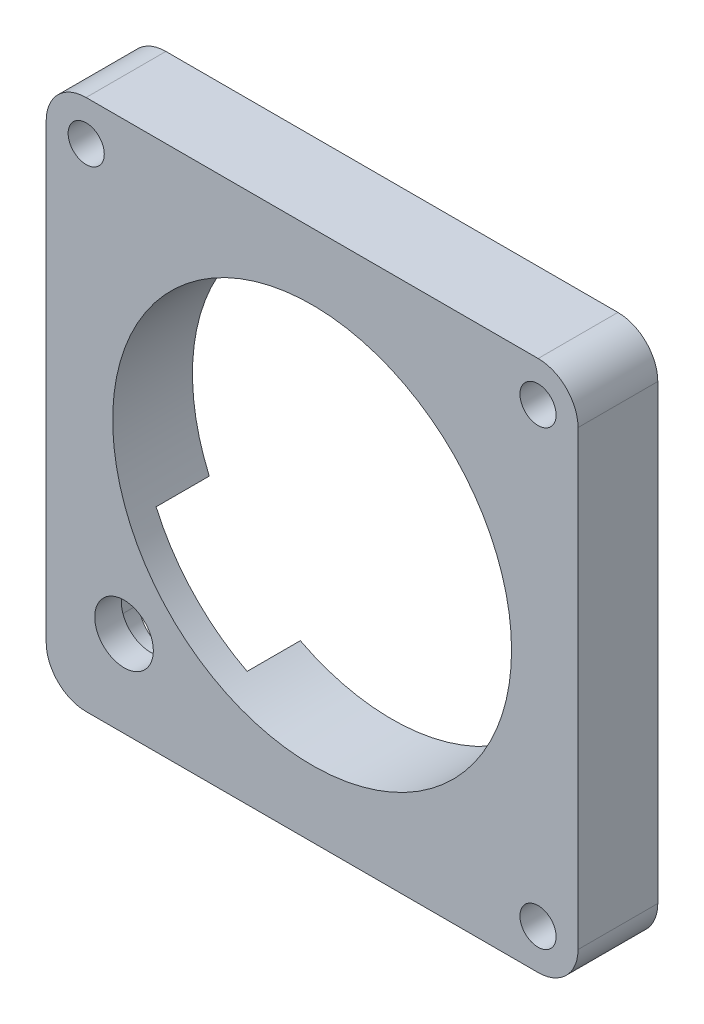
from build123d import *

# Parameters (mm, degrees)
SKETCH1_R                = 2.159
SKETCH1_R_2              = 28.5115
BOSS_EXTRUDE1_DEPTH      = 9.525
SKETCH1_4_R              = 28.5115
SKETCH1_4_R_2            = 23.8125
FLUSH_BEZEL_DEPTH        = 9.525
SKETCH1_5_R              = 28.5115
SKETCH1_5_R_2            = 23.8125
BOSS_EXTRUDE4_DEPTH      = 6.35
SKETCH2_R                = 25.3365
CUT_EXTRUDE1_DEPTH       = 7.35
CUT_EXTRUDE1_DEPTH_BACK  = 9.525
SKETCH3_R                = 28.5115
CUT_EXTRUDE2_DEPTH       = 7.35
SKETCH4_R                = 25.3365
SKETCH4_R_2              = 23.8125
BOSS_EXTRUDE7_DEPTH      = 1.5875
M6_CLEARANCE_HOLE1_D     = 7
M6_CLEARANCE_HOLE1_DEPTH = 9.525
BOSS_EXTRUDE8_REACH      = 11.525
SKETCH8_R                = 25.3365
SKETCH8_R_2              = 23.8125
CUT_EXTRUDE3_DEPTH       = 6.35
BOSS_EXTRUDE9_DEPTH      = 9.525


with BuildPart() as part:
    # Sketch1 → Boss-Extrude1 (new body)
    with BuildSketch(Plane.XY):
        with BuildLine():
            Line((-26.9875, 30.1625), (26.9875, 30.1625))
            ThreePointArc((26.9875, 30.1625), (29.23256403, 29.23256403), (30.1625, 26.9875))
            Line((30.1625, 26.9875), (30.1625, -26.9875))
            ThreePointArc((30.1625, -26.9875), (29.23256403, -29.23256403), (26.9875, -30.1625))
            Line((26.9875, -30.1625), (-26.9875, -30.1625))
            ThreePointArc((-26.9875, -30.1625), (-29.23256403, -29.23256403), (-30.1625, -26.9875))
            Line((-30.1625, -26.9875), (-30.1625, 26.9875))
            ThreePointArc((-30.1625, 26.9875), (-29.23256403, 29.23256403), (-26.9875, 30.1625))
        make_face()
        with Locations((-26.9748, 26.9748)):
            Circle(SKETCH1_R, mode=Mode.SUBTRACT)
        with Locations((26.9748, 26.9748)):
            Circle(SKETCH1_R, mode=Mode.SUBTRACT)
        with Locations((26.9748, -26.9748)):
            Circle(SKETCH1_R, mode=Mode.SUBTRACT)
        Circle(SKETCH1_R_2, mode=Mode.SUBTRACT)
    extrude(amount=BOSS_EXTRUDE1_DEPTH)

    # Sketch1_4 → Flush Bezel (add)
    with BuildSketch(Plane.XY):
        Circle(SKETCH1_4_R)
        Circle(SKETCH1_4_R_2, mode=Mode.SUBTRACT)
    extrude(amount=FLUSH_BEZEL_DEPTH)

    # Sketch1_5 → Boss-Extrude4 (add)
    with BuildSketch(Plane.XY):
        Circle(SKETCH1_5_R)
        Circle(SKETCH1_5_R_2, mode=Mode.SUBTRACT)
    extrude(amount=-BOSS_EXTRUDE4_DEPTH)

    # Sketch2 → Cut-Extrude1 (cut, two sides)
    with BuildSketch(Plane(origin=(0, 0, 0), x_dir=(-1, 0, 0), z_dir=(0, 0, -1))) as cut_extrude1_sk:
        Circle(SKETCH2_R)
    extrude(amount=CUT_EXTRUDE1_DEPTH, mode=Mode.SUBTRACT)
    extrude(cut_extrude1_sk.sketch, amount=-CUT_EXTRUDE1_DEPTH_BACK, mode=Mode.SUBTRACT)

    # Sketch3 → Cut-Extrude2 (cut, through all)
    with BuildSketch(Plane(origin=(0, 0, 0), x_dir=(-1, 0, 0), z_dir=(0, 0, -1))):
        Circle(SKETCH3_R)
    extrude(amount=CUT_EXTRUDE2_DEPTH, mode=Mode.SUBTRACT)

    # Sketch4 → Boss-Extrude7 (add)
    with BuildSketch(Plane.XY.offset(9.525)):
        Circle(SKETCH4_R)
        Circle(SKETCH4_R_2, mode=Mode.SUBTRACT)
    extrude(amount=-BOSS_EXTRUDE7_DEPTH)

    # M6 Clearance Hole1
    with Locations(Plane.XY.offset(9.525)):
        with Locations((-22.45595798, -21.4503)):
            Hole(M6_CLEARANCE_HOLE1_D / 2, depth=M6_CLEARANCE_HOLE1_DEPTH)

    # Sketch8 → Boss-Extrude8 (add, up to next)
    with BuildSketch(Plane(origin=(0, 0, 0), x_dir=(-1, 0, 0), z_dir=(0, 0, -1)), mode=Mode.PRIVATE) as boss_extrude8_sk1:
        Circle(SKETCH8_R)
        Circle(SKETCH8_R_2, mode=Mode.SUBTRACT)
    boss_extrude8_tool1 = extrude(boss_extrude8_sk1.sketch, amount=-BOSS_EXTRUDE8_REACH, mode=Mode.PRIVATE) - part.part
    add(boss_extrude8_tool1.solids().sort_by_distance((24.619876, 0, 0))[0])

    # Sketch9 → Cut-Extrude3 (cut)
    with BuildSketch(Plane(origin=(0, 0, 0), x_dir=(-1, 0, 0), z_dir=(0, 0, -1))):
        Polygon((25.823554026, -36.043216197), (37.048874177, -24.817896045), (19.088361935, -6.857383803), (7.863041784, -18.082703955), align=None)
    extrude(amount=-CUT_EXTRUDE3_DEPTH, mode=Mode.SUBTRACT)

    # Sketch10 → Boss-Extrude9 (add)
    with BuildSketch(Plane.XY.offset(9.525)):
        with BuildLine():
            Line((26.9875, 31.75), (-26.9875, 31.75))
            ThreePointArc((-26.9875, 31.75), (-30.355096045, 30.355096045), (-31.75, 26.9875))
            Line((-31.75, 26.9875), (-31.75, -26.9875))
            ThreePointArc((-31.75, -26.9875), (-30.355096045, -30.355096045), (-26.9875, -31.75))
            Line((-26.9875, -31.75), (26.9875, -31.75))
            ThreePointArc((26.9875, -31.75), (30.355096045, -30.355096045), (31.75, -26.9875))
            Line((31.75, -26.9875), (31.75, 26.9875))
            ThreePointArc((31.75, 26.9875), (30.355096045, 30.355096045), (26.9875, 31.75))
        make_face()
        with BuildLine():
            Line((26.9875, 30.1625), (-26.9875, 30.1625))
            ThreePointArc((-26.9875, 30.1625), (-29.23256403, 29.23256403), (-30.1625, 26.9875))
            Line((-30.1625, 26.9875), (-30.1625, -26.9875))
            ThreePointArc((-30.1625, -26.9875), (-29.23256403, -29.23256403), (-26.9875, -30.1625))
            Line((-26.9875, -30.1625), (26.9875, -30.1625))
            ThreePointArc((26.9875, -30.1625), (29.23256403, -29.23256403), (30.1625, -26.9875))
            Line((30.1625, -26.9875), (30.1625, 26.9875))
            ThreePointArc((30.1625, 26.9875), (29.23256403, 29.23256403), (26.9875, 30.1625))
        make_face(mode=Mode.SUBTRACT)
    extrude(amount=-BOSS_EXTRUDE9_DEPTH)


solid = part.part
